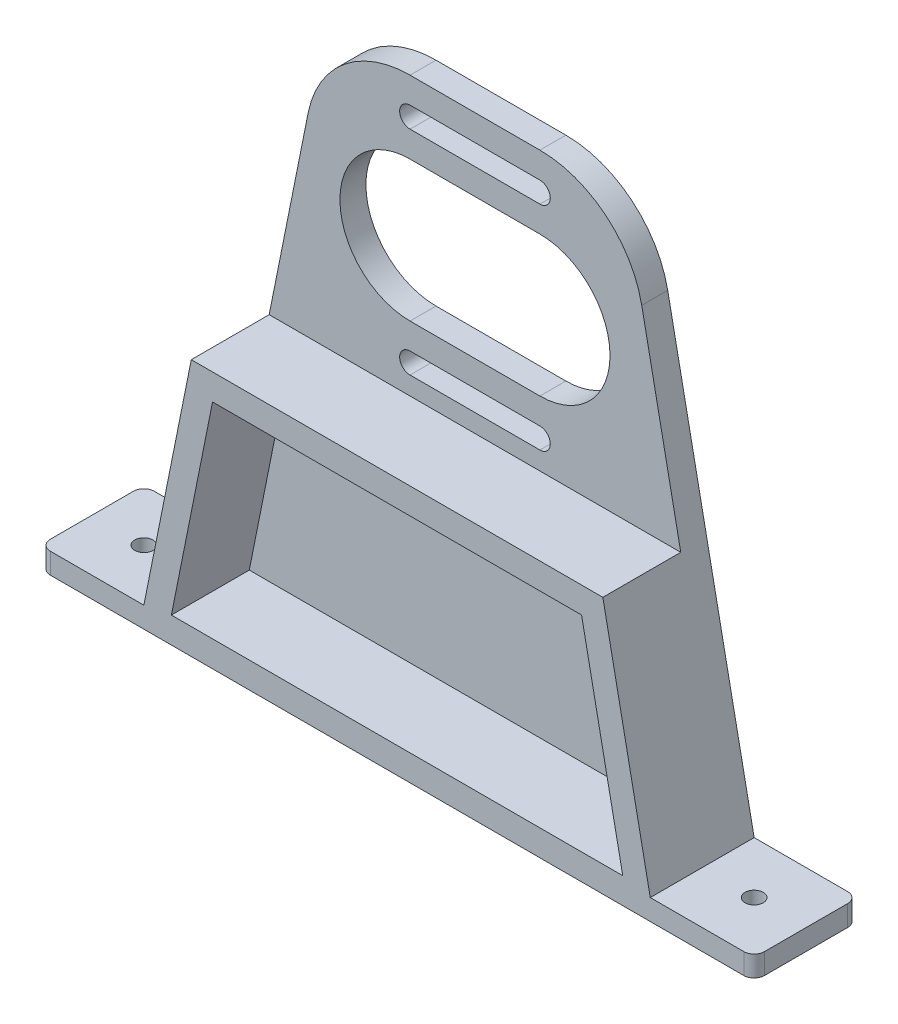
from build123d import *

# Parameters (mm, degrees)
BOSS_EXTRUDE1_DEPTH = 5
BOSS_EXTRUDE2_DEPTH = 15
SKETCH4_R           = 1.75
CUT_EXTRUDE1_DEPTH  = 5
FILLET2_R           = 2


with BuildPart() as part:
    # Sketch1 → Boss-Extrude1 (new body)
    with BuildSketch(Plane.XY):
        with BuildLine():
            Line((-68.75, 0), (68.75, 0))
            Line((68.75, 0), (68.75, 4))
            Line((68.75, 4), (48.75, 4))
            Line((48.75, 4), (32.109157698, 86.934581855))
            ThreePointArc((32.109157698, 86.934581855), (25.174943055, 98.470805362), (12.5, 103))
            Line((12.5, 103), (-12.5, 103))
            ThreePointArc((-12.5, 103), (-25.174943055, 98.470805362), (-32.109157698, 86.934581855))
            Line((-32.109157698, 86.934581855), (-48.75, 4))
            Line((-48.75, 4), (-68.75, 4))
            Line((-68.75, 4), (-68.75, 0))
        make_face()
        with BuildLine():
            Line((-12.5, 98), (12.5, 98))
            ThreePointArc((12.5, 98), (14.5, 96), (12.5, 94))
            Line((12.5, 94), (-12.5, 94))
            ThreePointArc((-12.5, 94), (-14.5, 96), (-12.5, 98))
        make_face(mode=Mode.SUBTRACT)
        with BuildLine():
            Line((-12.5, 89), (12.5, 89))
            ThreePointArc((12.5, 89), (26, 75.5), (12.5, 62))
            Line((12.5, 62), (-12.5, 62))
            ThreePointArc((-12.5, 62), (-26, 75.5), (-12.5, 89))
        make_face(mode=Mode.SUBTRACT)
        with BuildLine():
            Line((-12.5, 57), (12.5, 57))
            ThreePointArc((12.5, 57), (14.5, 55), (12.5, 53))
            Line((12.5, 53), (-12.5, 53))
            ThreePointArc((-12.5, 53), (-14.5, 55), (-12.5, 57))
        make_face(mode=Mode.SUBTRACT)
    extrude(amount=BOSS_EXTRUDE1_DEPTH)

    # Sketch2 → Boss-Extrude2 (add)
    with BuildSketch(Plane.XY.offset(5)):
        Polygon((-39.620414876, 49.5), (39.620414876, 49.5), (48.75, 4), (68.75, 4), (68.75, 0), (-68.75, 0), (-68.75, 4), (-48.75, 4), align=None)
        Polygon((-35.524007883, 44.5), (-43.449691672, 5), (43.449691672, 5), (35.524007883, 44.5), align=None, mode=Mode.SUBTRACT)
    extrude(amount=BOSS_EXTRUDE2_DEPTH)

    # Sketch4 → Cut-Extrude1 (cut, through all)
    with BuildSketch(Plane(origin=(0, 4, 0), x_dir=(1, 0, 0), z_dir=(0, 1, 0))):
        with Locations((-58.75, -10)):
            Circle(SKETCH4_R)
        with Locations((58.75, -10)):
            Circle(SKETCH4_R)
    extrude(amount=-CUT_EXTRUDE1_DEPTH, mode=Mode.SUBTRACT)

    # Fillet2
    fillet2_edges = [part.edges().sort_by_distance(p)[0] for p in [
        (68.75, 2, 0),
        (-68.75, 2, 0),
        (-68.75, 2, 20),
        (68.75, 2, 20),
    ]]
    fillet(fillet2_edges, radius=FILLET2_R)


solid = part.part
